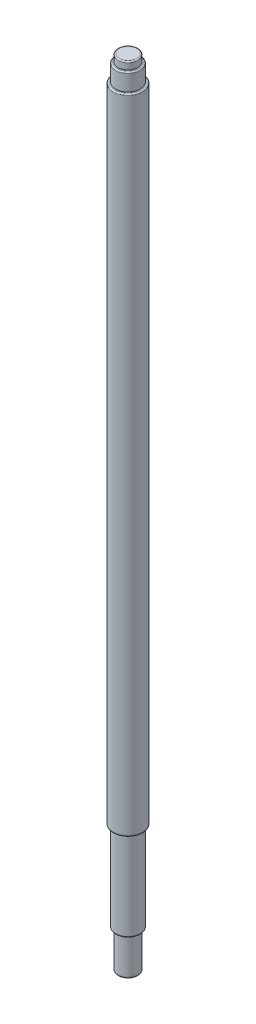
from build123d import *

# Parameters (mm, degrees)
SKETCH_1_R      = 4
EXTRUDE_1_DEPTH = 15
SKETCH_2_R      = 5
EXTRUDE_2_DEPTH = 36
SKETCH_3_R      = 6
EXTRUDE_3_DEPTH = 260
SKETCH_4_R      = 5
EXTRUDE_4_DEPTH = 7
SKETCH_5_R      = 4
EXTRUDE_5_DEPTH = 3
FILLET_1_R      = 0.5
FILLET_2_R      = 0.5
FILLET_3_R      = 0.5
FILLET_4_R      = 0.5
FILLET_5_R      = 0.5
FILLET_6_R      = 0.5


with BuildPart() as part:
    # 草图1 → 凸台-拉伸1 (new body)
    with BuildSketch(Plane(origin=(0, 0, 0), x_dir=(1, 0, 0), z_dir=(0, 1, 0))):
        Circle(SKETCH_1_R)
    extrude(amount=EXTRUDE_1_DEPTH)

    # 草图2 → 凸台-拉伸2 (add)
    with BuildSketch(Plane(origin=(0, 15, 0), x_dir=(1, 0, 0), z_dir=(0, 1, 0))):
        Circle(SKETCH_2_R)
    extrude(amount=EXTRUDE_2_DEPTH)

    # 草图3 → 凸台-拉伸3 (add)
    with BuildSketch(Plane(origin=(0, 51, 0), x_dir=(1, 0, 0), z_dir=(0, 1, 0))):
        Circle(SKETCH_3_R)
    extrude(amount=EXTRUDE_3_DEPTH)

    # 草图4 → 凸台-拉伸4 (add)
    with BuildSketch(Plane(origin=(0, 311, 0), x_dir=(1, 0, 0), z_dir=(0, 1, 0))):
        Circle(SKETCH_4_R)
    extrude(amount=EXTRUDE_4_DEPTH)

    # 草图5 → 凸台-拉伸5 (add)
    with BuildSketch(Plane(origin=(0, 318, 0), x_dir=(1, 0, 0), z_dir=(0, 1, 0))):
        Circle(SKETCH_5_R)
    extrude(amount=EXTRUDE_5_DEPTH)

    # 圆角1
    fillet_1_edges = [part.edges().sort_by_distance(p)[0] for p in [
        (-4, 321, 0),
    ]]
    fillet(fillet_1_edges, radius=FILLET_1_R)

    # 圆角2
    fillet_2_edges = [part.edges().sort_by_distance(p)[0] for p in [
        (-5, 318, 0),
    ]]
    fillet(fillet_2_edges, radius=FILLET_2_R)

    # 圆角3
    fillet_3_edges = [part.edges().sort_by_distance(p)[0] for p in [
        (-6, 311, 0),
    ]]
    fillet(fillet_3_edges, radius=FILLET_3_R)

    # 圆角4
    fillet_4_edges = [part.edges().sort_by_distance(p)[0] for p in [
        (-6, 51, 0),
    ]]
    fillet(fillet_4_edges, radius=FILLET_4_R)

    # 圆角5
    fillet_5_edges = [part.edges().sort_by_distance(p)[0] for p in [
        (-5, 15, 0),
    ]]
    fillet(fillet_5_edges, radius=FILLET_5_R)

    # 圆角6
    fillet_6_edges = [part.edges().sort_by_distance(p)[0] for p in [
        (-4, 0, 0),
    ]]
    fillet(fillet_6_edges, radius=FILLET_6_R)


solid = part.part
